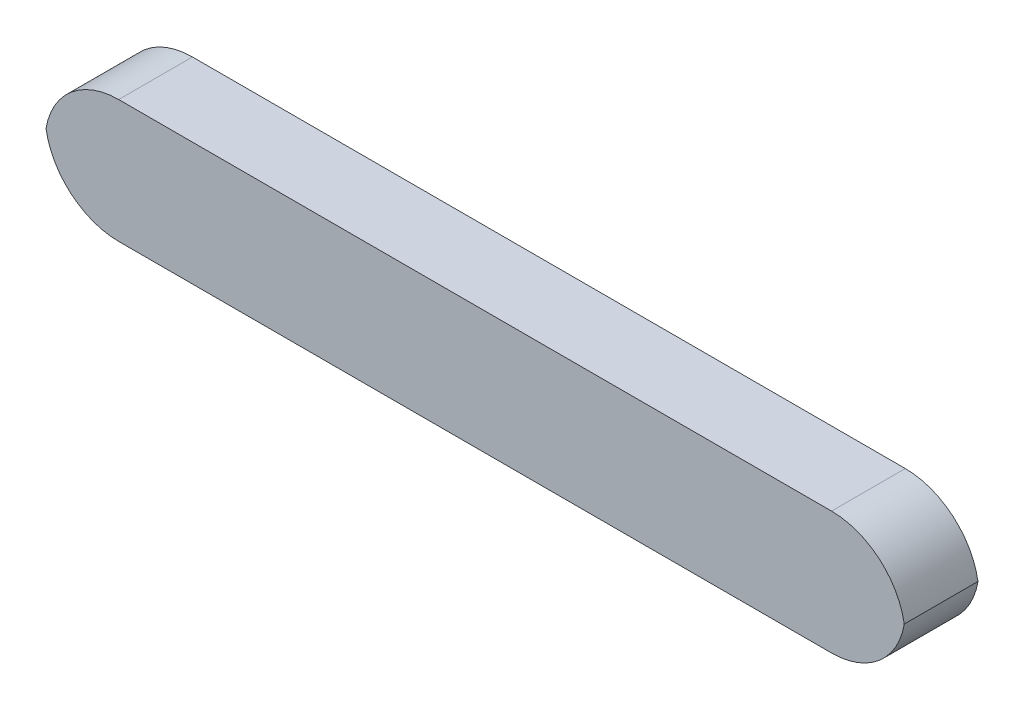
from build123d import *

# Parameters (mm, degrees)
SALIENTE_EXTRUIR1_DEPTH = 30


with BuildPart() as part:
    # Croquis1 → Saliente-Extruir1 (new body)
    with BuildSketch(Plane.XY):
        with BuildLine():
            Line((-145, -25), (145, -25))
            ThreePointArc((145, -25), (164.364916731, -17.912878475), (174.580398915, 0))
            ThreePointArc((174.580398915, 0), (164.364916731, 17.912878475), (145, 25))
            Line((145, 25), (-145, 25))
            ThreePointArc((-145, 25), (-164.364916731, 17.912878475), (-174.580398915, 0))
            ThreePointArc((-174.580398915, 0), (-164.364916731, -17.912878475), (-145, -25))
        make_face()
    extrude(amount=SALIENTE_EXTRUIR1_DEPTH)


solid = part.part
